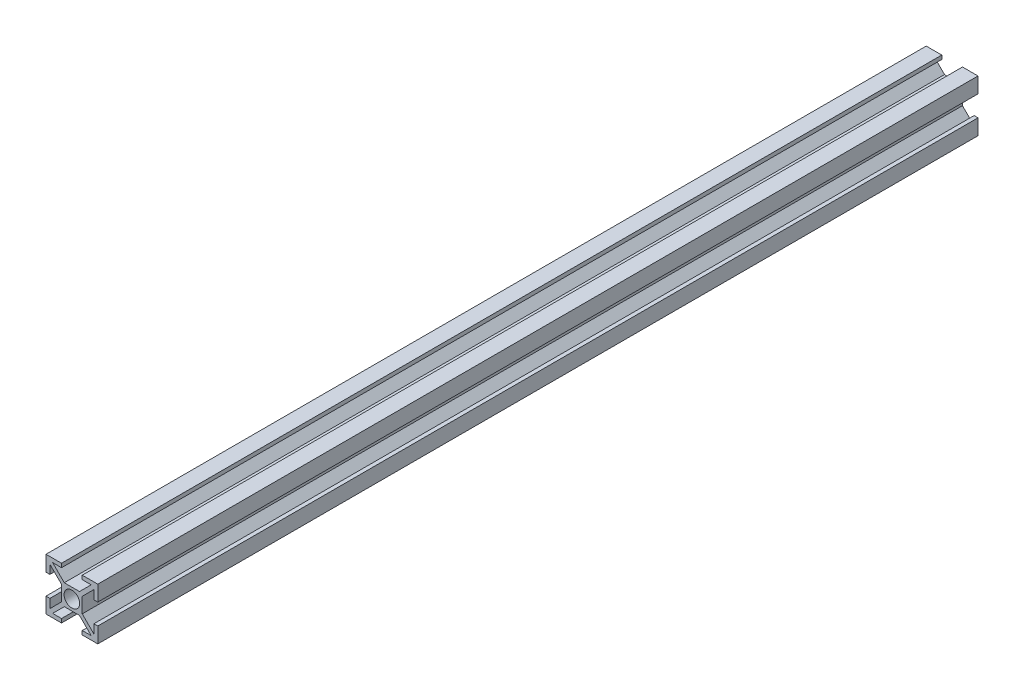
from build123d import *

# Parameters (mm, degrees)
ESBO_O1_R                = 3
RESSALTO_EXTRUS_O1_DEPTH = 340


with BuildPart() as part:
    # Esboço1 → Ressalto-extrusão1 (new body)
    with BuildSketch(Plane.XY):
        Polygon((-2.939339828, 4), (2.939339828, 4), (7.439339828, 8.5), (4, 8.5), (4, 10), (10, 10), (10, 4), (8.5, 4), (8.5, 7.439339828), (4, 2.939339828), (4, -2.939339828), (8.5, -7.439339828), (8.5, -4), (10, -4), (10, -10), (4, -10), (4, -8.5), (7.439339828, -8.5), (2.939339828, -4), (-2.939339828, -4), (-7.439339828, -8.5), (-4, -8.5), (-4, -10), (-10, -10), (-10, -4), (-8.5, -4), (-8.5, -7.439339828), (-4, -2.939339828), (-4, 2.939339828), (-8.5, 7.439339828), (-8.5, 4), (-10, 4), (-10, 10), (-4, 10), (-4, 8.5), (-7.439339828, 8.5), align=None)
        Circle(ESBO_O1_R, mode=Mode.SUBTRACT)
    extrude(amount=RESSALTO_EXTRUS_O1_DEPTH)


solid = part.part
